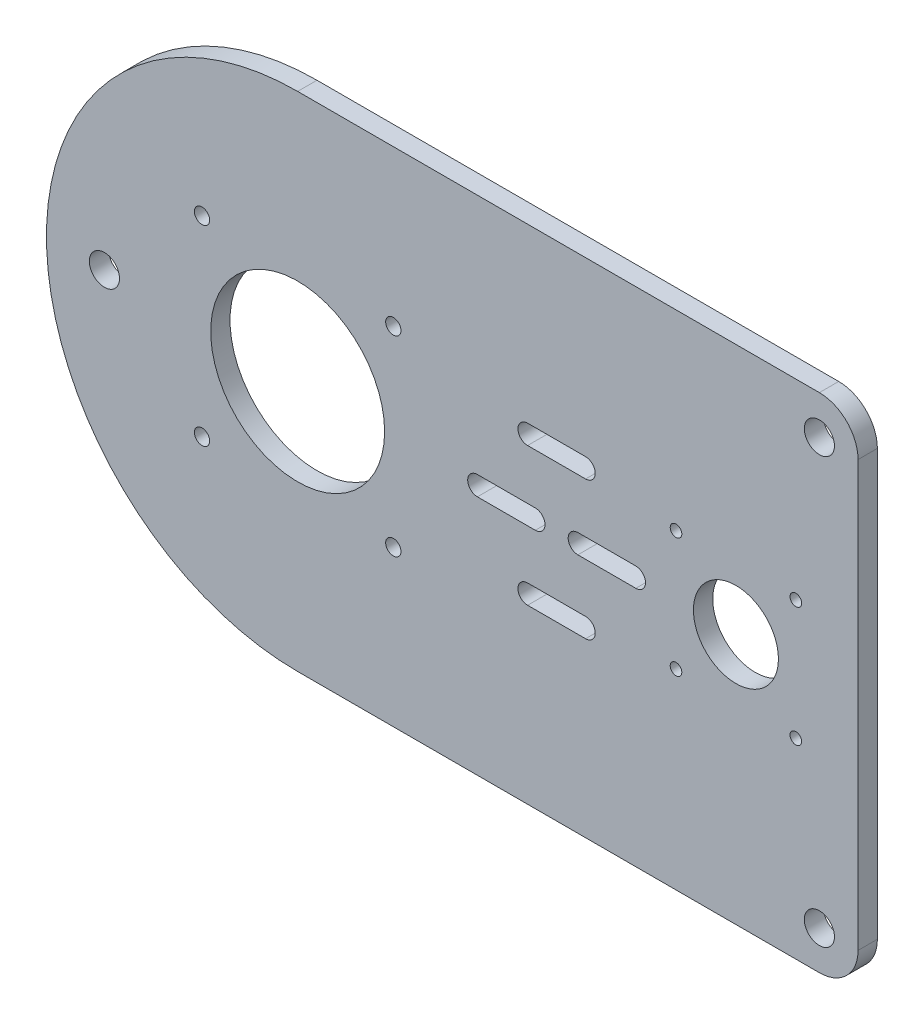
from build123d import *

# Parameters (mm, degrees)
SKETCH1_R           = 3.9
SKETCH1_R_2         = 22.5
SKETCH1_R_3         = 1.975
SKETCH1_R_4         = 11
SKETCH1_R_5         = 1.5
BOSS_EXTRUDE3_DEPTH = 5


with BuildPart() as part:
    # Sketch1 → Boss-Extrude3 (new body)
    with BuildSketch(Plane.XY):
        with BuildLine():
            Line((-40, -65), (95, -65))
            ThreePointArc((95, -65), (102.071067812, -62.071067812), (105, -55))
            Line((105, -55), (105, 55))
            ThreePointArc((105, 55), (102.071067812, 62.071067812), (95, 65))
            Line((95, 65), (-40, 65))
            ThreePointArc((-40, 65), (-105, 0), (-40, -65))
        make_face()
        with Locations((95, 55)):
            Circle(SKETCH1_R, mode=Mode.SUBTRACT)
        with Locations((95, -55)):
            Circle(SKETCH1_R, mode=Mode.SUBTRACT)
        with Locations((-90, 0)):
            Circle(SKETCH1_R, mode=Mode.SUBTRACT)
        with Locations((-40, 0)):
            Circle(SKETCH1_R_2, mode=Mode.SUBTRACT)
        with Locations((-64.75, 24.75)):
            Circle(SKETCH1_R_3, mode=Mode.SUBTRACT)
        with Locations((-15.25, 24.75)):
            Circle(SKETCH1_R_3, mode=Mode.SUBTRACT)
        with Locations((-15.25, -24.75)):
            Circle(SKETCH1_R_3, mode=Mode.SUBTRACT)
        with Locations((-64.75, -24.75)):
            Circle(SKETCH1_R_3, mode=Mode.SUBTRACT)
        with Locations((73.4, 0)):
            Circle(SKETCH1_R_4, mode=Mode.SUBTRACT)
        with Locations((57.9, 15.5)):
            Circle(SKETCH1_R_5, mode=Mode.SUBTRACT)
        with Locations((88.9, 15.5)):
            Circle(SKETCH1_R_5, mode=Mode.SUBTRACT)
        with Locations((88.9, -15.5)):
            Circle(SKETCH1_R_5, mode=Mode.SUBTRACT)
        with Locations((57.9, -15.5)):
            Circle(SKETCH1_R_5, mode=Mode.SUBTRACT)
        with BuildLine():
            Line((32.5, 2.4), (47.5, 2.4))
            ThreePointArc((47.5, 2.4), (50, -0.1), (47.5, -2.6))
            Line((47.5, -2.6), (32.5, -2.6))
            ThreePointArc((32.5, -2.6), (30, -0.1), (32.5, 2.4))
        make_face(mode=Mode.SUBTRACT)
        with BuildLine():
            Line((19.5, 20.4), (34.5, 20.4))
            ThreePointArc((34.5, 20.4), (37, 17.9), (34.5, 15.4))
            Line((34.5, 15.4), (19.5, 15.4))
            ThreePointArc((19.5, 15.4), (17, 17.9), (19.5, 20.4))
        make_face(mode=Mode.SUBTRACT)
        with BuildLine():
            Line((21.5, 2.4), (6.5, 2.4))
            ThreePointArc((6.5, 2.4), (4, -0.1), (6.5, -2.6))
            Line((6.5, -2.6), (21.5, -2.6))
            ThreePointArc((21.5, -2.6), (24, -0.1), (21.5, 2.4))
        make_face(mode=Mode.SUBTRACT)
        with BuildLine():
            Line((34.5, -15.4), (19.5, -15.4))
            ThreePointArc((19.5, -15.4), (17, -17.9), (19.5, -20.4))
            Line((19.5, -20.4), (34.5, -20.4))
            ThreePointArc((34.5, -20.4), (37, -17.9), (34.5, -15.4))
        make_face(mode=Mode.SUBTRACT)
    extrude(amount=BOSS_EXTRUDE3_DEPTH)


solid = part.part
